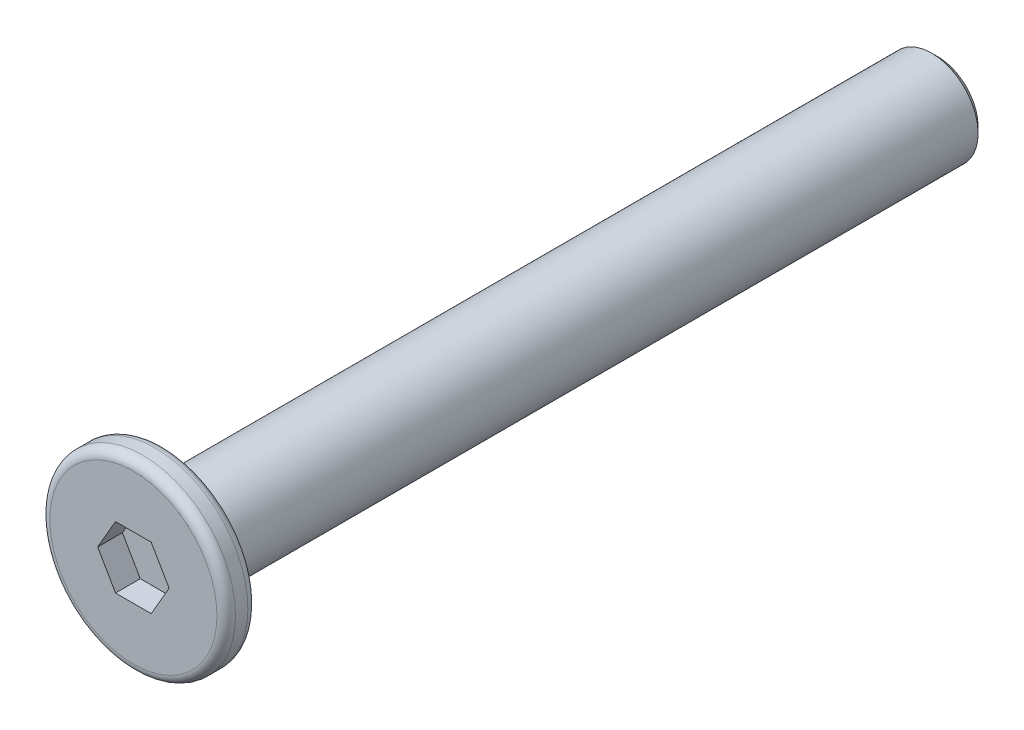
from build123d import *

# Parameters (mm, degrees)
SKETCH_1_R          = 3
EXTRUDE_1_DEPTH     = 0.5
SKETCH_2_R          = 1.5
EXTRUDE_2_DEPTH     = 25
CHAMFER_1_SIZE      = 0.2
CUT_EXTRUDE_1_DEPTH = 0.8
FILLET_2_R          = 0.3


with BuildPart() as part:
    # 草图1 → 凸台-拉伸1 (new body, symmetric)
    with BuildSketch(Plane.XY):
        Circle(SKETCH_1_R)
    extrude(amount=EXTRUDE_1_DEPTH, both=True)

    # 草图2 → 凸台-拉伸2 (add)
    with BuildSketch(Plane(origin=(0, 0, -0.5), x_dir=(-1, 0, 0), z_dir=(0, 0, -1))):
        Circle(SKETCH_2_R)
    extrude(amount=EXTRUDE_2_DEPTH)

    # 倒角1
    chamfer_1_edges = [part.edges().sort_by_distance(p)[0] for p in [
        (1.5, 0, -25.5),
    ]]
    chamfer(chamfer_1_edges, length=CHAMFER_1_SIZE)

    # 草图3 → 切除-拉伸1 (cut)
    with BuildSketch(Plane.XY.offset(0.5)):
        Polygon((1.154700538, 0), (0.577350269, 1), (-0.577350269, 1), (-1.154700538, 0), (-0.577350269, -1), (0.577350269, -1), align=None)
    extrude(amount=-CUT_EXTRUDE_1_DEPTH, mode=Mode.SUBTRACT)

    # 圆角2
    fillet_2_edges = [part.edges().sort_by_distance(p)[0] for p in [
        (-3, 0, -0.5),
        (-3, 0, 0.5),
    ]]
    fillet(fillet_2_edges, radius=FILLET_2_R)


solid = part.part
